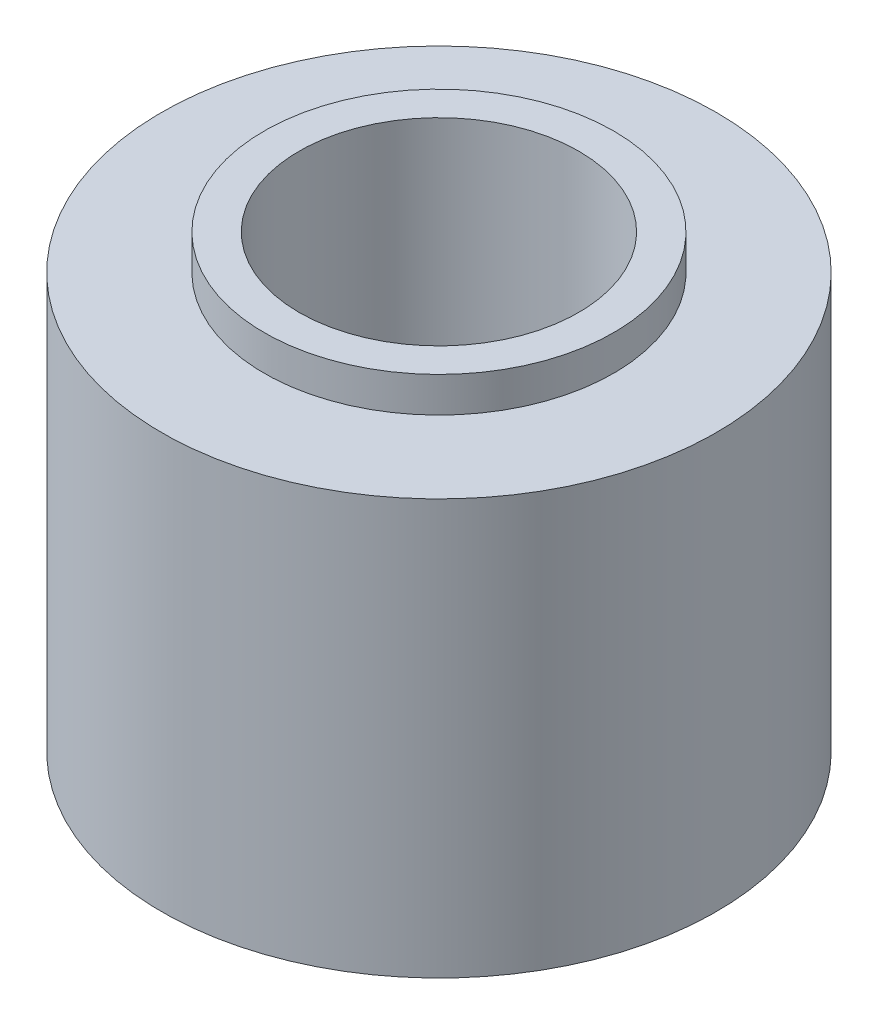
from build123d import *

# Parameters (mm, degrees)
SKETCH1_W = 3.1496
SKETCH1_H = 11.1125
SKETCH2_W = 2.35
SKETCH2_H = 0.80625


with BuildPart() as part:
    # Sketch1 → Revolve1 (revolve)
    with BuildSketch(Plane.XY):
        with Locations((4.7752, 0)):
            Rectangle(SKETCH1_W, SKETCH1_H)
    revolve(axis=Axis((0, 5.55625, 0), (0, -1, 0)))

    # Sketch2 → Cut-Revolve1 (revolve, cut)
    with BuildSketch(Plane.XY):
        with Locations((-5.175, 5.153125)):
            Rectangle(SKETCH2_W, SKETCH2_H)
        with Locations((-5.175, -5.153125)):
            Rectangle(SKETCH2_W, SKETCH2_H)
    revolve(axis=Axis((0, -6.044864414, 0), (0, 1, 0)), mode=Mode.SUBTRACT)


solid = part.part
